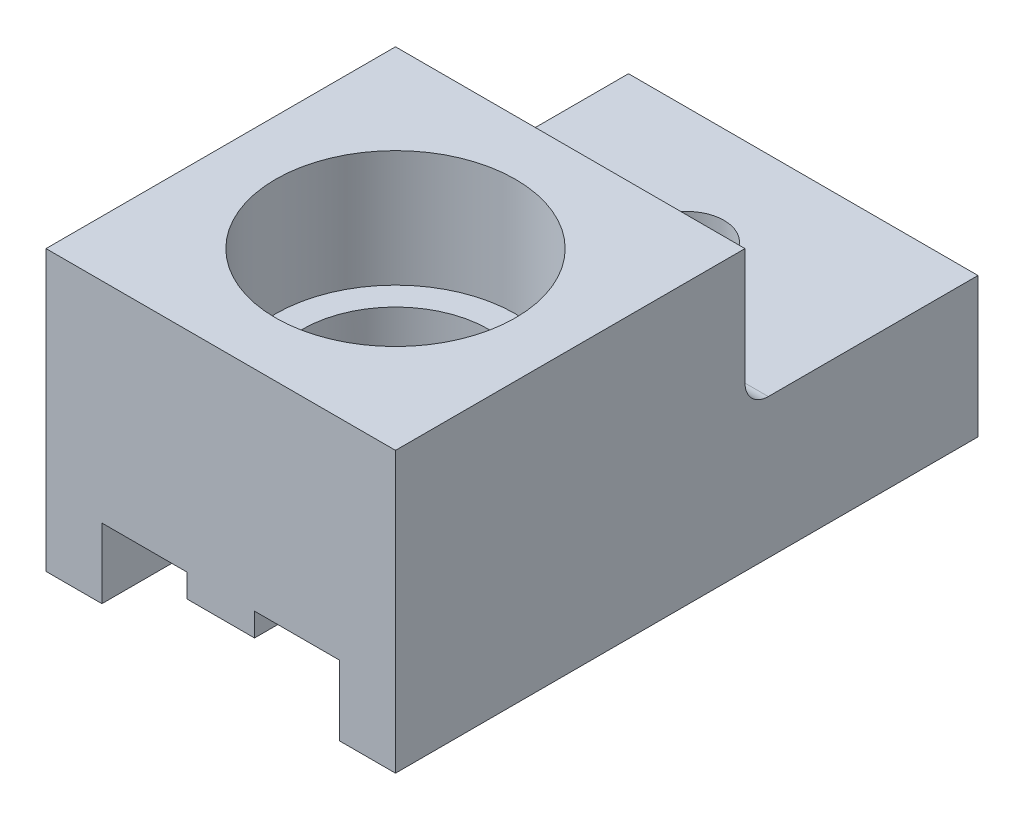
from build123d import *

# Parameters (mm, degrees)
MAIN_DEPTH         = 25
SKETCH2_R          = 5.15
ROLLINGHOLE_DEPTH  = 5
SKETCH3_R          = 4
CUT_EXTRUDE2_DEPTH = 8
SKETCH4_R          = 1.6
FIXHOLE_DEPTH      = 13
SKETCH5_W          = 10
SKETCH5_H          = 6
CUT_EXTRUDE4_DEPTH = 16
FILLET1_R          = 1


with BuildPart() as part:
    # Sketch1 → Main (new body)
    with BuildSketch(Plane.XY):
        Polygon((-5.1, 0), (-5.1, -3), (-7.5, -3), (-7.5, 9), (7.5, 9), (7.5, -3), (5.1, -3), (5.1, 0), (1.45, 0), (1.45, -1), (-1.45, -1), (-1.45, 0), align=None)
    extrude(amount=MAIN_DEPTH)

    # Sketch2 → RollingHole (cut)
    with BuildSketch(Plane(origin=(0, 9, 0), x_dir=(1, 0, 0), z_dir=(0, 1, 0))):
        with Locations((0, -17.5)):
            Circle(SKETCH2_R)
    extrude(amount=-ROLLINGHOLE_DEPTH, mode=Mode.SUBTRACT)

    # Sketch3 → Cut-Extrude2 (cut, through all)
    with BuildSketch(Plane(origin=(0, 4, 0), x_dir=(1, 0, 0), z_dir=(0, 1, 0))):
        with Locations((0, -17.5)):
            Circle(SKETCH3_R)
    extrude(amount=-CUT_EXTRUDE2_DEPTH, mode=Mode.SUBTRACT)

    # Sketch4 → FixHole (cut, through all)
    with BuildSketch(Plane(origin=(0, 9, 0), x_dir=(1, 0, 0), z_dir=(0, 1, 0))):
        with Locations((0, -5)):
            Circle(SKETCH4_R)
    extrude(amount=-FIXHOLE_DEPTH, mode=Mode.SUBTRACT)

    # Sketch5 → Cut-Extrude4 (cut, through all)
    with BuildSketch(Plane.ZY.offset(7.5)):
        with Locations((5, 6)):
            Rectangle(SKETCH5_W, SKETCH5_H)
    extrude(amount=-CUT_EXTRUDE4_DEPTH, mode=Mode.SUBTRACT)

    # Fillet1
    fillet1_edges = [part.edges().sort_by_distance(p)[0] for p in [
        (0, 3, 10),
    ]]
    fillet(fillet1_edges, radius=FILLET1_R)


solid = part.part
